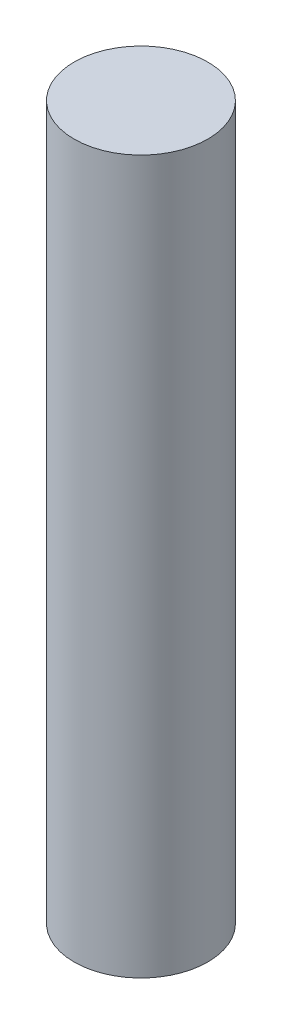
from build123d import *

# Parameters (mm, degrees)
SKETCH1_R           = 1.5
BOSS_EXTRUDE1_DEPTH = 16


with BuildPart() as part:
    # Sketch1 → Boss-Extrude1 (new body)
    with BuildSketch(Plane(origin=(0, 0, 0), x_dir=(1, 0, 0), z_dir=(0, 1, 0))):
        Circle(SKETCH1_R)
    extrude(amount=BOSS_EXTRUDE1_DEPTH)


solid = part.part
